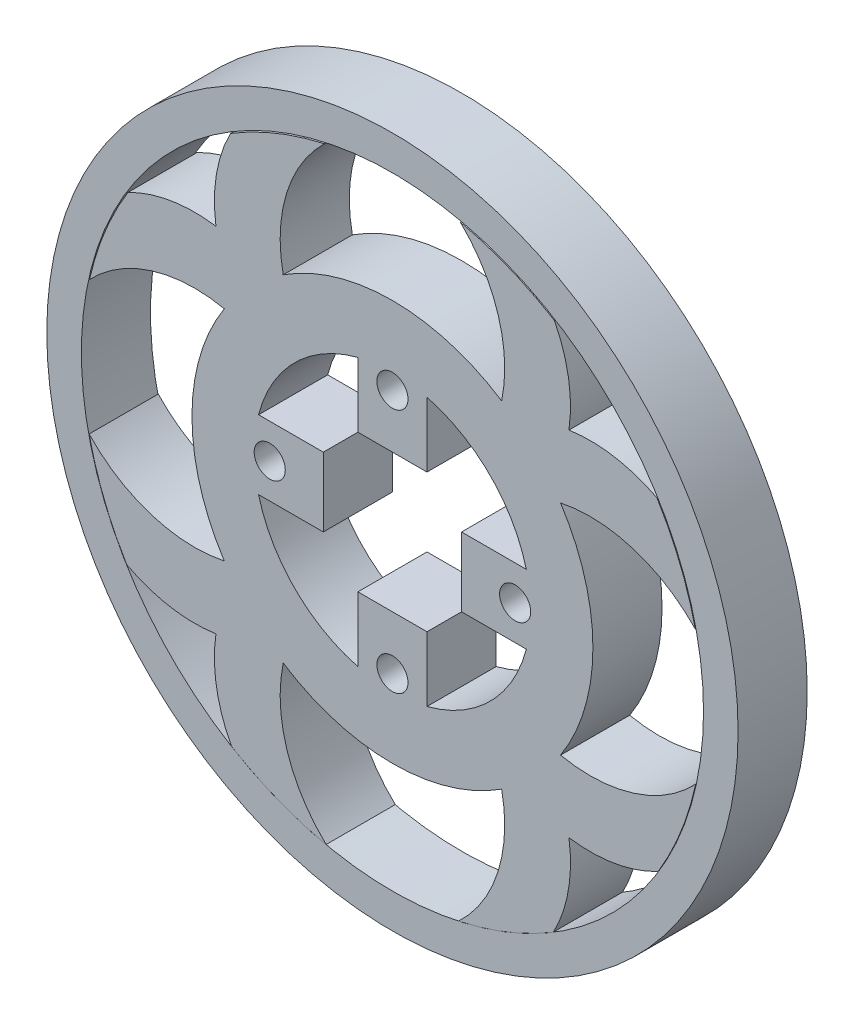
from build123d import *

# Parameters (mm, degrees)
SKETCH6_R                    = 29
SKETCH6_R_2                  = 20
INNER_RING_DEPTH             = 10
MOTOR_CONNECTOR_CUT_DEPTH    = 10
SKETCH9_R                    = 50
SKETCH9_R_2                  = 29
OUTSIDE_RING_EXTRUSION_DEPTH = 10
SKETCH12_R                   = 45
SKETCH12_R_2                 = 27.5
CUT_EXTRUDE6_DEPTH           = 55
SKETCH8_R                    = 2.25
MOTOR_CONNECTOR_HOLES_DEPTH  = 10
SKETCH10_R                   = 27.404299948
BOSS_EXTRUDE4_DEPTH          = 10


with BuildPart() as part:
    # Sketch6 → Inner Ring (new body)
    with BuildSketch(Plane.XY):
        Circle(SKETCH6_R)
        Circle(SKETCH6_R_2, mode=Mode.SUBTRACT)
    extrude(amount=-INNER_RING_DEPTH)

    # Sketch7 → Motor Connector Cut (add)
    with BuildSketch(Plane.XY):
        with BuildLine():
            ThreePointArc((20, 0), (19.840593925, 2.52008585), (19.364916731, 5))
            Line((19.364916731, 5), (9.999996731, 5))
            Line((9.999996731, 5), (9.999996731, -5))
            Line((9.999996731, -5), (19.364916731, -5))
            ThreePointArc((19.364916731, -5), (19.840593925, -2.52008585), (20, 0))
        make_face()
        with BuildLine():
            ThreePointArc((5, 19.364916731), (0, 20), (-5, 19.364916731))
            Line((-5, 19.364916731), (-5, 9.999996731))
            Line((-5, 9.999996731), (5, 9.999996731))
            Line((5, 9.999996731), (5, 19.364916731))
        make_face()
        with BuildLine():
            Line((-9.999996731, -5), (-9.999996731, 5))
            Line((-9.999996731, 5), (-19.364916731, 5))
            ThreePointArc((-19.364916731, 5), (-20, 0), (-19.364916731, -5))
            Line((-19.364916731, -5), (-9.999996731, -5))
        make_face()
        with BuildLine():
            Line((-5, -9.999996731), (-5, -19.364916731))
            ThreePointArc((-5, -19.364916731), (0, -20), (5, -19.364916731))
            Line((5, -19.364916731), (5, -9.999996731))
            Line((5, -9.999996731), (-5, -9.999996731))
        make_face()
    extrude(amount=-MOTOR_CONNECTOR_CUT_DEPTH)

    # Sketch9 → Outside Ring Extrusion (add)
    with BuildSketch(Plane.XY):
        Circle(SKETCH9_R)
        Circle(SKETCH9_R_2, mode=Mode.SUBTRACT)
    extrude(amount=-OUTSIDE_RING_EXTRUSION_DEPTH)

    # Sketch12 → Cut-Extrude6 (cut)
    with BuildSketch(Plane.XY):
        Circle(SKETCH12_R)
        Circle(SKETCH12_R_2, mode=Mode.SUBTRACT)
    extrude(amount=-CUT_EXTRUDE6_DEPTH, mode=Mode.SUBTRACT)

    # Sketch8 → Motor Connector Holes (cut)
    with BuildSketch(Plane.XY):
        with Locations((0, 17.75)):
            Circle(SKETCH8_R)
        with Locations((17.75, 0)):
            Circle(SKETCH8_R)
        with Locations((0, -17.75)):
            Circle(SKETCH8_R)
        with Locations((-17.75, 0)):
            Circle(SKETCH8_R)
    extrude(amount=-MOTOR_CONNECTOR_HOLES_DEPTH, mode=Mode.SUBTRACT)

    # Sketch10 → Boss-Extrude4 (add)
    with BuildSketch(Plane.XY):
        with BuildLine():
            ThreePointArc((24.317625284, 15.800414568), (34.856582319, 15.291767932), (43.817916626, 9.721954269))
            ThreePointArc((43.817916626, 9.721954269), (41.607188912, 16.793289988), (38.263814419, 23.404867172))
            ThreePointArc((38.263814419, 23.404867172), (32.064348025, 25.470287935), (25.530148518, 25.530148518))
            ThreePointArc((25.530148518, 25.530148518), (25.475284033, 32.034279432), (23.432821057, 38.209639668))
            ThreePointArc((23.432821057, 38.209639668), (20.212556871, 40.002288656), (16.856128399, 41.524812789))
            ThreePointArc((16.856128399, 41.524812789), (13.384732217, 42.767397097), (9.823095744, 43.720997037))
            ThreePointArc((9.823095744, 43.720997037), (15.312499865, 34.789679765), (15.800414568, 24.317625284))
            ThreePointArc((15.800414568, 24.317625284), (0, 29), (-15.800414568, 24.317625284))
            ThreePointArc((-15.800414568, 24.317625284), (-15.312499865, 34.789679765), (-9.823095744, 43.720997037))
            ThreePointArc((-9.823095744, 43.720997037), (-16.854754984, 41.52536899), (-23.432821057, 38.209639668))
            ThreePointArc((-23.432821057, 38.209639668), (-25.475284033, 32.034279432), (-25.530148518, 25.530148518))
            ThreePointArc((-25.530148518, 25.530148518), (-32.064348025, 25.470287935), (-38.263814419, 23.404867172))
            ThreePointArc((-38.263814419, 23.404867172), (-41.607188912, 16.793289988), (-43.817916626, 9.721954269))
            ThreePointArc((-43.817916626, 9.721954269), (-34.856582319, 15.291767932), (-24.317625284, 15.800414568))
            ThreePointArc((-24.317625284, 15.800414568), (-29, 0), (-24.317625284, -15.800414568))
            ThreePointArc((-24.317625284, -15.800414568), (-34.894848495, -15.279799844), (-43.87309253, -9.663767027))
            ThreePointArc((-43.87309253, -9.663767027), (-41.716263612, -16.713446711), (-38.435015504, -23.315212041))
            ThreePointArc((-38.435015504, -23.315212041), (-32.159621016, -25.454161245), (-25.530148518, -25.530148518))
            ThreePointArc((-25.530148518, -25.530148518), (-25.448803812, -32.190695038), (-23.285614603, -38.490703716))
            ThreePointArc((-23.285614603, -38.490703716), (-16.649731385, -41.799208281), (-9.559859326, -43.970581744))
            ThreePointArc((-9.559859326, -43.970581744), (-15.258354287, -34.962784804), (-15.800414568, -24.317625284))
            ThreePointArc((-15.800414568, -24.317625284), (0, -29), (15.800414568, -24.317625284))
            ThreePointArc((15.800414568, -24.317625284), (15.258354287, -34.962784804), (9.559859326, -43.970581744))
            ThreePointArc((9.559859326, -43.970581744), (16.649731385, -41.799208281), (23.285614603, -38.490703716))
            ThreePointArc((23.285614603, -38.490703716), (25.448803812, -32.190695038), (25.530148518, -25.530148518))
            ThreePointArc((25.530148518, -25.530148518), (32.159621016, -25.454161245), (38.435015504, -23.315212041))
            ThreePointArc((38.435015504, -23.315212041), (41.716263612, -16.713446711), (43.87309253, -9.663767027))
            ThreePointArc((43.87309253, -9.663767027), (34.894848495, -15.279799844), (24.317625284, -15.800414568))
            ThreePointArc((24.317625284, -15.800414568), (29, 0), (24.317625284, 15.800414568))
        make_face()
        with Locations((-0.095700052, 0)):
            Circle(SKETCH10_R, mode=Mode.SUBTRACT)
    extrude(amount=-BOSS_EXTRUDE4_DEPTH)


solid = part.part
